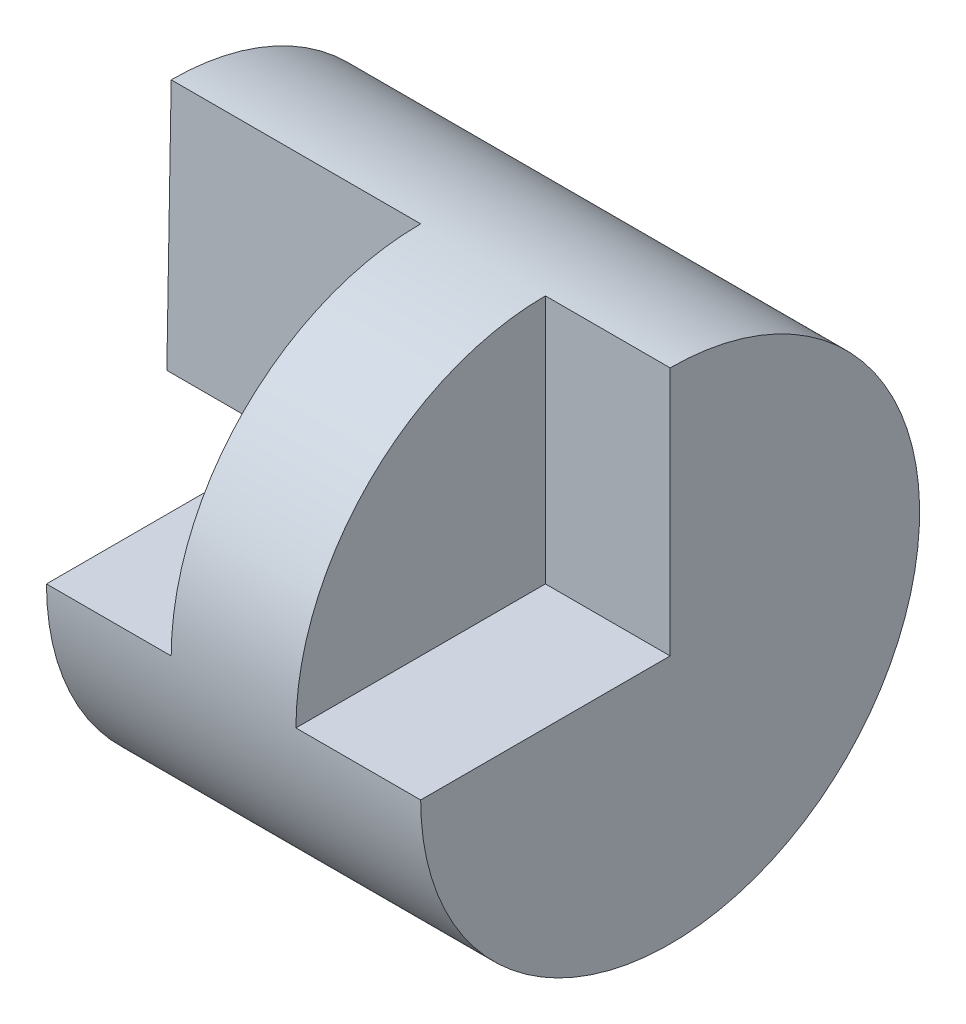
from build123d import *

# Parameters (mm, degrees)
SKETCH5_W           = 4
SKETCH5_H           = 2
SKETCH6_W           = 1
SKETCH6_H           = 2
CUT_EXTRUDE5_DEPTH  = 11
SKETCH8_W           = 0.5
SKETCH8_H           = 2
CUT_EXTRUDE7_DEPTH  = 10
SKETCH9_W           = 1.5
SKETCH9_H           = 2
CUT_EXTRUDE8_DEPTH  = 10
BOSS_EXTRUDE1_DEPTH = 4
SKETCH13_W          = 4.449870591
SKETCH13_H          = 3.198188742
CUT_EXTRUDE10_DEPTH = 1
SKETCH14_W          = 1
SKETCH14_H          = 2
CUT_EXTRUDE11_DEPTH = 10


with BuildPart() as part:
    # Sketch5 → Revolve-Thin2 (revolve)
    with BuildSketch(Plane.XY):
        with Locations((2, 1)):
            Rectangle(SKETCH5_W, SKETCH5_H)
    revolve(axis=Axis((0, 0, 0), (1, 0, 0)))

    # Sketch6 → Cut-Extrude5 (cut)
    with BuildSketch(Plane.XY):
        with Locations((3.5, 1)):
            Rectangle(SKETCH6_W, SKETCH6_H)
        with Locations((0.5, 1)):
            Rectangle(SKETCH6_W, SKETCH6_H)
    extrude(amount=-CUT_EXTRUDE5_DEPTH, mode=Mode.SUBTRACT)

    # Sketch8 → Cut-Extrude7 (cut)
    with BuildSketch(Plane(origin=(0, 0, 0), x_dir=(-1, 0, 0), z_dir=(0, 0, -1))):
        with Locations((-0.25, 1)):
            Rectangle(SKETCH8_W, SKETCH8_H)
    extrude(amount=-CUT_EXTRUDE7_DEPTH, mode=Mode.SUBTRACT)

    # Sketch9 → Cut-Extrude8 (cut)
    with BuildSketch(Plane(origin=(0, 0, 0), x_dir=(-1, 0, 0), z_dir=(0, 0, -1))):
        with Locations((-1.25, 1)):
            Rectangle(SKETCH9_W, SKETCH9_H)
    extrude(amount=-CUT_EXTRUDE8_DEPTH, mode=Mode.SUBTRACT)

    # Sketch10 → Boss-Extrude1 (add)
    with BuildSketch(Plane(origin=(4, 0, 0), x_dir=(0, 0, -1), z_dir=(1, 0, 0))):
        with BuildLine():
            Line((2, 0), (-0.034977088, 0))
            Line((-0.034977088, 0), (0, 2))
            ThreePointArc((0, 2), (1.414213562, 1.414213562), (2, 0))
        make_face()
    extrude(amount=-BOSS_EXTRUDE1_DEPTH)

    # Sketch13 → Cut-Extrude10 (cut)
    with BuildSketch(Plane.ZY):
        with Locations((-0.224935296, -1.599094371)):
            Rectangle(SKETCH13_W, SKETCH13_H)
    extrude(amount=-CUT_EXTRUDE10_DEPTH, mode=Mode.SUBTRACT)

    # Sketch14 → Cut-Extrude11 (cut)
    with BuildSketch(Plane.XY):
        with Locations((3.5, 1)):
            Rectangle(SKETCH14_W, SKETCH14_H)
    extrude(amount=CUT_EXTRUDE11_DEPTH, mode=Mode.SUBTRACT)


solid = part.part
